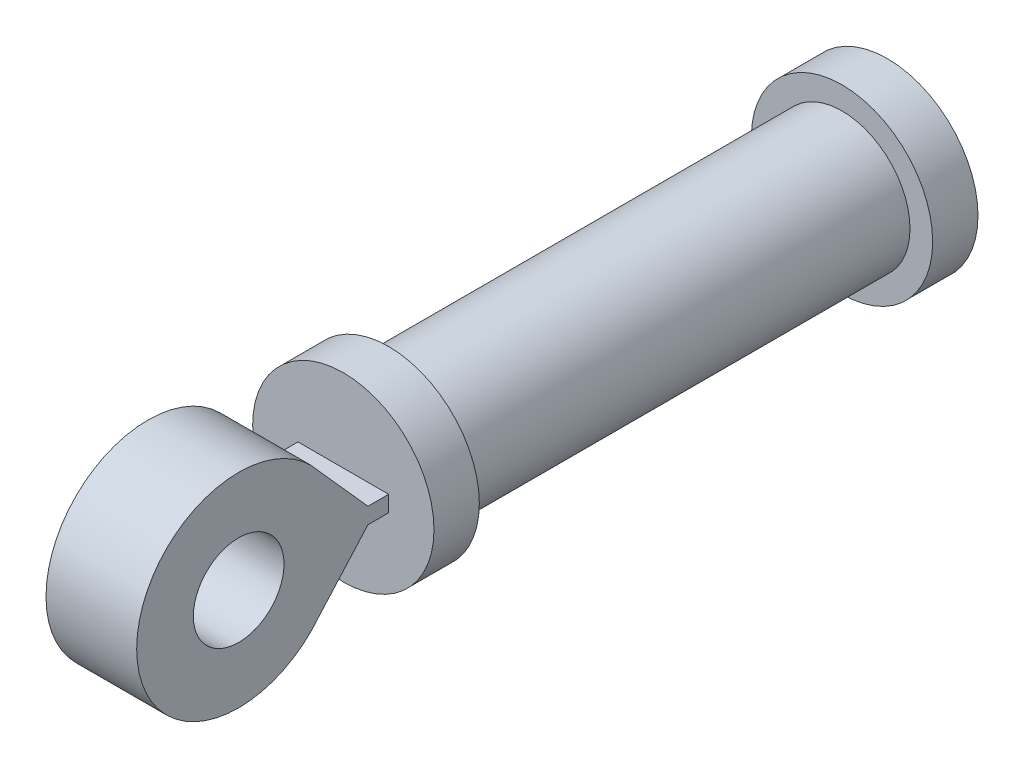
from build123d import *

# Parameters (mm, degrees)
SKETCH3_R           = 10
BOSS_EXTRUDE3_DEPTH = 5
SKETCH16_R          = 7.5
BOSS_EXTRUDE7_DEPTH = 50
SKETCH19_R          = 4
CUT_EXTRUDE3_DEPTH  = 50
SKETCH20_R          = 10
BOSS_EXTRUDE8_DEPTH = 5
SKETCH21_W          = 103.138410702
SKETCH21_H          = 76.113402372
BOSS_EXTRUDE9_DEPTH = 70
SCALE1_SCALE        = 2
SKETCH31_R          = 10
CUT_EXTRUDE11_DEPTH = 207.276821406
SKETCH32_W          = 93.138410703
SKETCH32_H          = 55.584947452
CUT_EXTRUDE12_DEPTH = 40


with BuildPart() as part:
    # Sketch3 → Boss-Extrude3 (new body)
    with BuildSketch(Plane.XY):
        Circle(SKETCH3_R)
    extrude(amount=BOSS_EXTRUDE3_DEPTH)

    # Sketch14 → CBORE for M4 Cheese Head Screw1 (revolve, cut)
    with BuildSketch(Plane(origin=(0, 0, 5), x_dir=(0, -1, 0), z_dir=(1, 0, 0))):
        Polygon((0, 0), (0, 8.942065486), (2.4, 7.5), (2.4, 2.6), (4, 2.6), (4, 0.025), (4.025, 0), align=None)
    revolve(axis=Axis((0, 0, 11.35), (0, 0, -1)), mode=Mode.SUBTRACT)

    # Sketch16 → Boss-Extrude7 (add)
    with BuildSketch(Plane.XY.offset(5)):
        Circle(SKETCH16_R)
    extrude(amount=BOSS_EXTRUDE7_DEPTH)

    # Sketch19 → Cut-Extrude3 (cut)
    with BuildSketch(Plane.XY.offset(55)):
        Circle(SKETCH19_R)
    extrude(amount=-CUT_EXTRUDE3_DEPTH, mode=Mode.SUBTRACT)

    # Sketch20 → Boss-Extrude8 (add)
    with BuildSketch(Plane.XY.offset(55)):
        Circle(SKETCH20_R)
    extrude(amount=BOSS_EXTRUDE8_DEPTH)

    # Sketch21 → Boss-Extrude9 (add)
    with BuildSketch(Plane.XY.offset(60)):
        Rectangle(SKETCH21_W, SKETCH21_H)
    extrude(amount=BOSS_EXTRUDE9_DEPTH)


with BuildPart() as part_1:
    # Scale1: scaled about (0, 0, 93.927789278)
    add(part.part.scale(SCALE1_SCALE).moved(Location((0, 0, -93.927789278))))

    # Sketch31 → Cut-Extrude11 (cut, through all)
    with BuildSketch(Plane(origin=(103.138410703, 0, 0), x_dir=(0, 0, -1), z_dir=(1, 0, 0))):
        with BuildLine():
            Line((-30.633863687, 1.766654317), (-26.072210722, 1.766654317))
            Line((-26.072210722, 1.766654317), (-26.072210722, 76.113402371))
            Line((-26.072210722, 76.113402371), (-166.072210722, 76.113402371))
            Line((-166.072210722, 76.113402371), (-166.072210722, -76.113402371))
            Line((-166.072210722, -76.113402371), (-26.072210722, -76.113402371))
            Line((-26.072210722, -76.113402371), (-26.072210722, -1.766654317))
            Line((-26.072210722, -1.766654317), (-30.633863687, -1.766654317))
            Line((-30.633863687, -1.766654317), (-41.414995548, -13.837111886))
            ThreePointArc((-41.414995548, -13.837111886), (-81.657158174, 0), (-41.414995548, 13.837111886))
            Line((-41.414995548, 13.837111886), (-30.633863687, 1.766654317))
        make_face()
        Polygon((-166.072210722, 76.113402371), (-26.072210722, 76.113402371), (-26.072210722, 93.777305116), (-178.92688661, 93.777305116), (-178.92688661, -90.381530622), (-26.072210722, -90.381530622), (-26.072210722, -76.113402371), (-166.072210722, -76.113402371), align=None)
        with Locations((-59.157158174, 0)):
            Circle(SKETCH31_R)
    extrude(amount=-CUT_EXTRUDE11_DEPTH, mode=Mode.SUBTRACT)

    # Sketch32 → Cut-Extrude12 (cut, symmetric)
    with BuildSketch(Plane(origin=(0, 1.766654317, 0), x_dir=(1, 0, 0), z_dir=(0, 1, 0))):
        with Locations((-56.569205352, -53.864684448)):
            Rectangle(SKETCH32_W, SKETCH32_H)
        with Locations((56.569205352, -53.864684448)):
            Rectangle(SKETCH32_W, SKETCH32_H)
    extrude(amount=CUT_EXTRUDE12_DEPTH, both=True, mode=Mode.SUBTRACT)


solid = part_1.part
